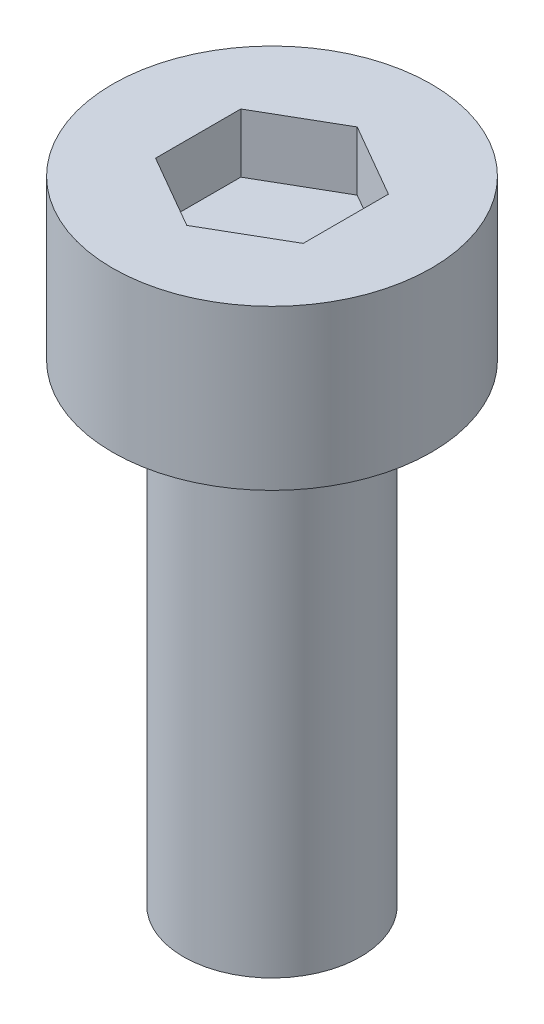
from build123d import *

# Parameters (mm, degrees)
SKETCH1_R           = 2.7
BOSS_EXTRUDE1_DEPTH = 2.7
CUT_EXTRUDE1_DEPTH  = 1
SKETCH3_R           = 1.5
BOSS_EXTRUDE2_DEPTH = 8


with BuildPart() as part:
    # Sketch1 → Boss-Extrude1 (new body)
    with BuildSketch(Plane(origin=(0, 0, 0), x_dir=(1, 0, 0), z_dir=(0, 1, 0))):
        Circle(SKETCH1_R)
    extrude(amount=BOSS_EXTRUDE1_DEPTH)

    # Sketch2 → Cut-Extrude1 (cut)
    with BuildSketch(Plane(origin=(0, 2.7, 0), x_dir=(1, 0, 0), z_dir=(0, 1, 0))):
        Polygon((0, 1.443375673), (-1.25, 0.721687836), (-1.25, -0.721687836), (0, -1.443375673), (1.25, -0.721687836), (1.25, 0.721687836), align=None)
    extrude(amount=-CUT_EXTRUDE1_DEPTH, mode=Mode.SUBTRACT)

    # Sketch3 → Boss-Extrude2 (add)
    with BuildSketch(Plane.XZ):
        Circle(SKETCH3_R)
    extrude(amount=BOSS_EXTRUDE2_DEPTH)


solid = part.part
